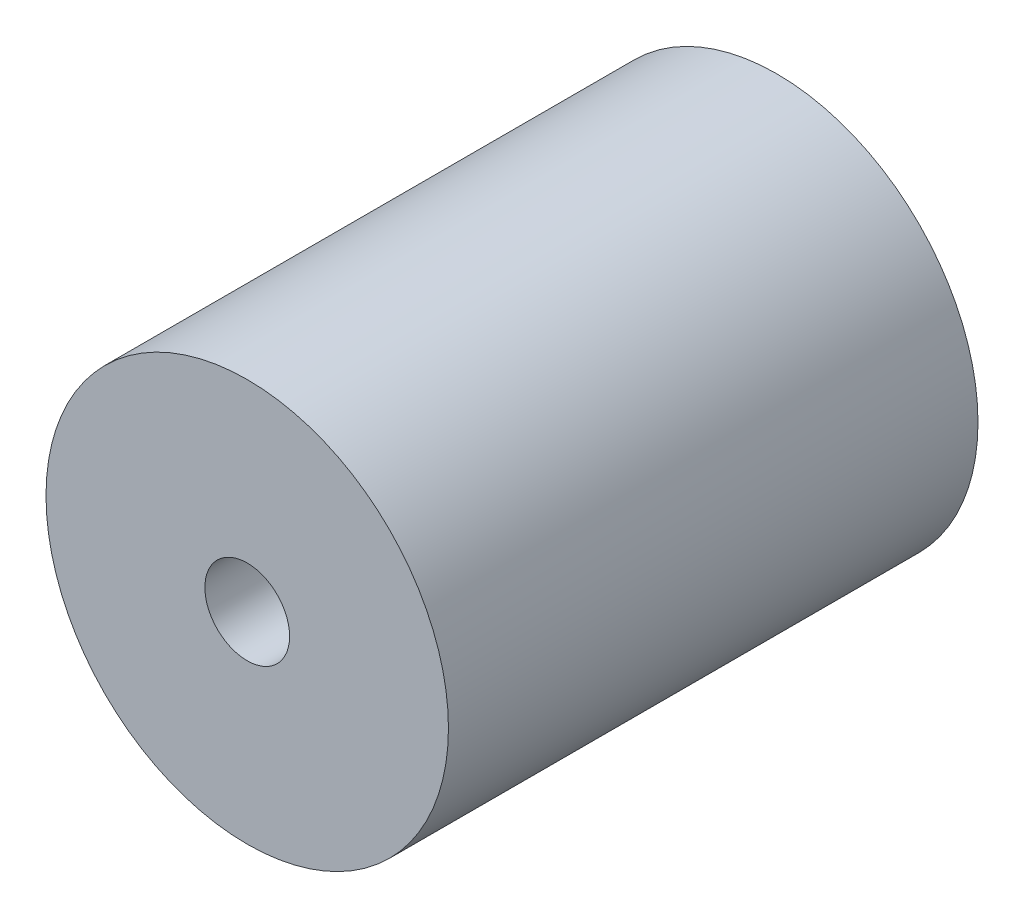
from build123d import *

# Parameters (mm, degrees)
SKETCH1_R           = 9.5
BOSS_EXTRUDE1_DEPTH = 25
SKETCH2_R           = 2
CUT_EXTRUDE1_DEPTH  = 26
SKETCH3_R           = 5
CUT_EXTRUDE2_DEPTH  = 12.5


with BuildPart() as part:
    # Sketch1 → Boss-Extrude1 (new body)
    with BuildSketch(Plane.XY):
        Circle(SKETCH1_R)
    extrude(amount=BOSS_EXTRUDE1_DEPTH)

    # Sketch2 → Cut-Extrude1 (cut, through all)
    with BuildSketch(Plane.XY.offset(25)):
        Circle(SKETCH2_R)
    extrude(amount=-CUT_EXTRUDE1_DEPTH, mode=Mode.SUBTRACT)

    # Sketch3 → Cut-Extrude2 (cut)
    with BuildSketch(Plane(origin=(0, 0, 0), x_dir=(-1, 0, 0), z_dir=(0, 0, -1))):
        Circle(SKETCH3_R)
    extrude(amount=-CUT_EXTRUDE2_DEPTH, mode=Mode.SUBTRACT)


solid = part.part
